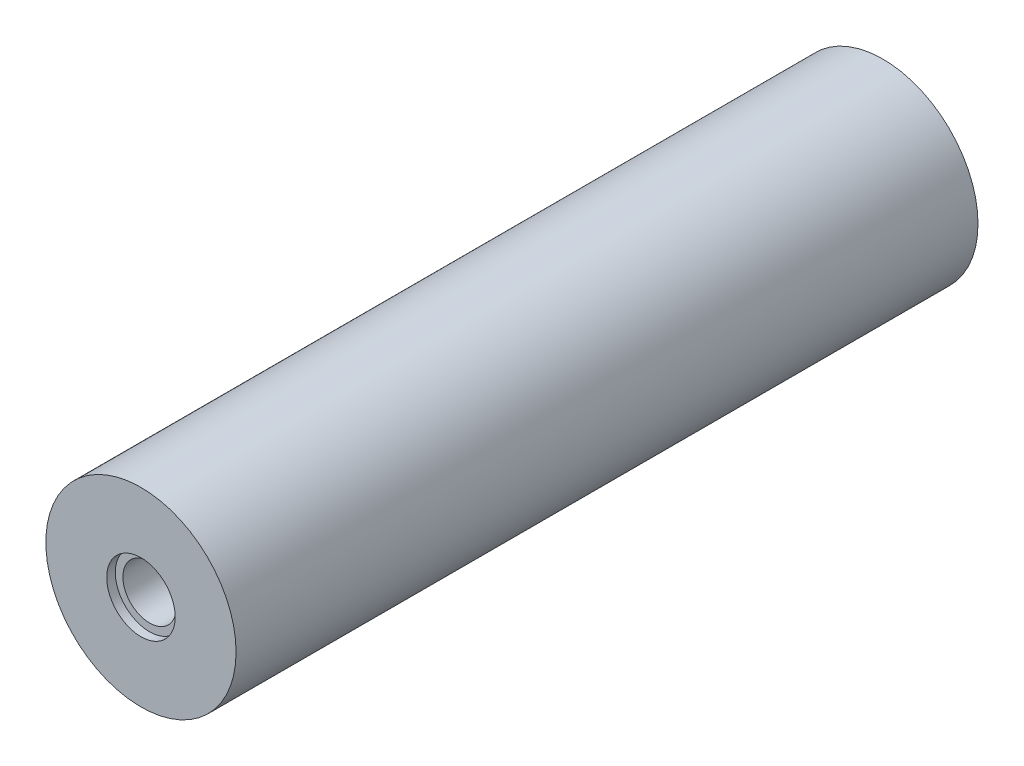
from build123d import *

# Parameters (mm, degrees)
SKETCH1_R           = 10
BOSS_EXTRUDE1_DEPTH = 78
SKETCH2_R           = 2.8
CUT_EXTRUDE1_DEPTH  = 20
SKETCH3_R           = 3.6
CUT_EXTRUDE2_DEPTH  = 0.9
SKETCH4_R           = 1.8
CUT_EXTRUDE3_DEPTH  = 20
CHAMFER2_SIZE       = 2
CHAMFER2_SIZE2      = 0.352653961


with BuildPart() as part:
    # Sketch1 → Boss-Extrude1 (new body)
    with BuildSketch(Plane.XY):
        Circle(SKETCH1_R)
    extrude(amount=BOSS_EXTRUDE1_DEPTH)

    # Sketch2 → Cut-Extrude1 (cut)
    with BuildSketch(Plane.XY.offset(78)):
        Circle(SKETCH2_R)
    extrude(amount=-CUT_EXTRUDE1_DEPTH, mode=Mode.SUBTRACT)

    # Sketch3 → Cut-Extrude2 (cut)
    with BuildSketch(Plane.XY.offset(78)):
        Circle(SKETCH3_R)
    extrude(amount=-CUT_EXTRUDE2_DEPTH, mode=Mode.SUBTRACT)

    # Sketch4 → Cut-Extrude3 (cut)
    with BuildSketch(Plane(origin=(0, 0, 0), x_dir=(-1, 0, 0), z_dir=(0, 0, -1))):
        Circle(SKETCH4_R)
    extrude(amount=-CUT_EXTRUDE3_DEPTH, mode=Mode.SUBTRACT)

    # Chamfer2
    chamfer2_edges = [part.edges().sort_by_distance(p)[0] for p in [
        (1.8, 0, 0),
    ]]
    chamfer2_side = [part.faces().sort_by_distance(p)[0] for p in [
        (1.8, 0, 10),
    ]]
    chamfer(chamfer2_edges, length=CHAMFER2_SIZE, length2=CHAMFER2_SIZE2, reference=chamfer2_side[0])


solid = part.part
